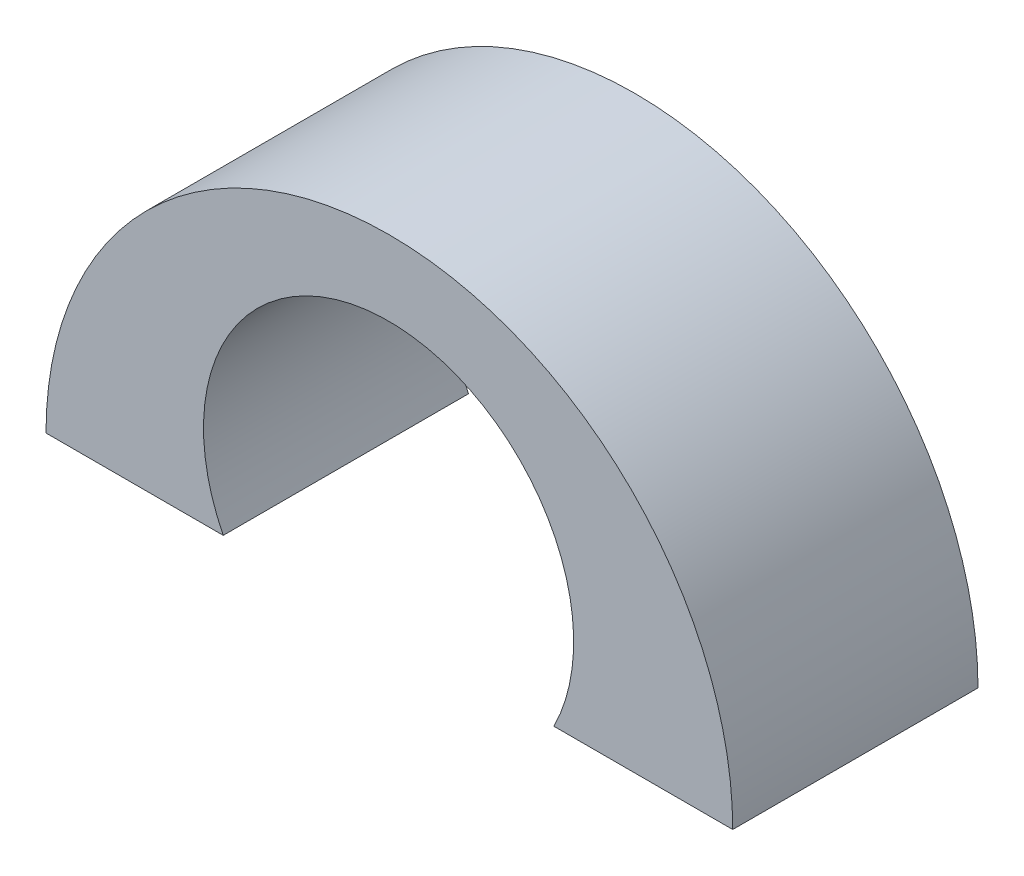
from build123d import *

# Parameters (mm, degrees)
BOSS_EXTRU_1_DEPTH = 5


with BuildPart() as part:
    # Esquisse1 → Boss.-Extru.1 (new body)
    with BuildSketch(Plane.XY):
        with BuildLine():
            Line((-3.386485683, 0), (-7, 0))
            ThreePointArc((-7, 0), (0, 7), (7, 0))
            Line((7, 0), (3.354457295, 0))
            ThreePointArc((3.354457295, 0), (-0.016014194, 5.468913046), (-3.386485683, 0))
        make_face()
    extrude(amount=BOSS_EXTRU_1_DEPTH)


solid = part.part
